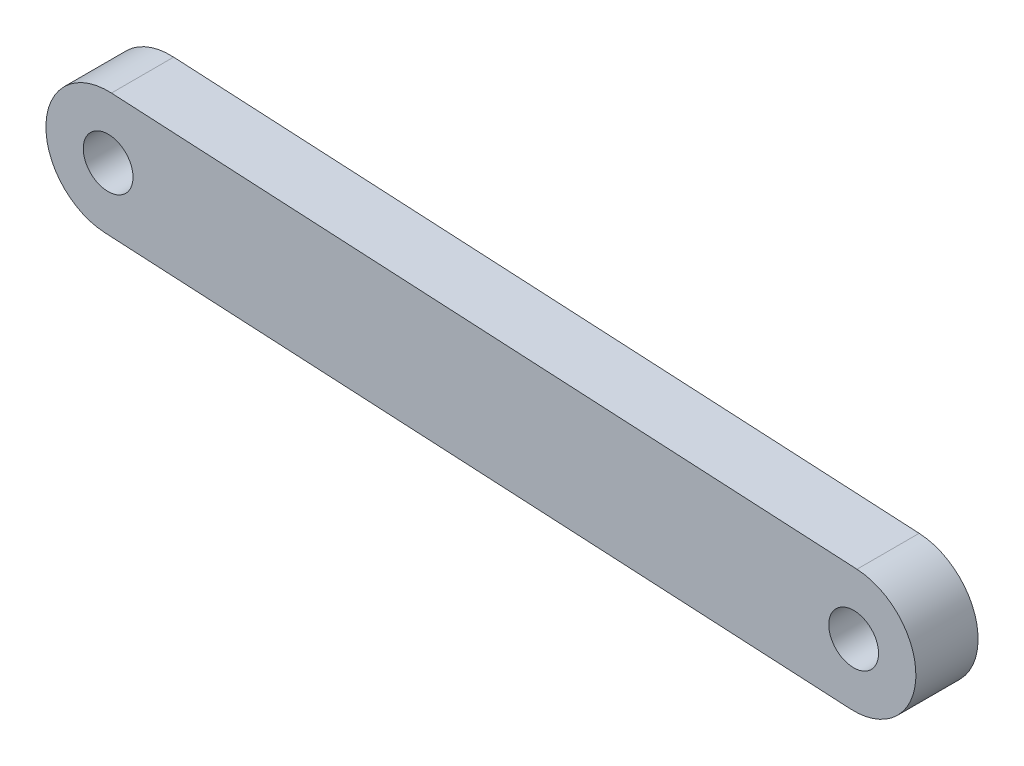
from build123d import *

# Parameters (mm, degrees)
SKETCH1_R           = 2
BOSS_EXTRUDE1_DEPTH = 5


with BuildPart() as part:
    # Sketch1 → Boss-Extrude1 (new body)
    with BuildSketch(Plane(origin=(0, 0, 0), x_dir=(0.431181775, 0.902265081, 0), z_dir=(0, 0, 1))):
        with BuildLine():
            Line((-18.654834307, 30.177729369), (-41.615840249, 85.610501319))
            ThreePointArc((-41.615840249, 85.610501319), (-48.148655073, 88.31648182), (-50.854635574, 81.783666996))
            Line((-50.854635574, 81.783666996), (-27.893629632, 26.350895045))
            ThreePointArc((-27.893629632, 26.350895045), (-21.360814808, 23.644914544), (-18.654834307, 30.177729369))
        make_face()
        with Locations((-23.27423197, 28.264312207)):
            Circle(SKETCH1_R, mode=Mode.SUBTRACT)
        with Locations((-46.235237911, 83.697084158)):
            Circle(SKETCH1_R, mode=Mode.SUBTRACT)
    extrude(amount=BOSS_EXTRUDE1_DEPTH)


solid = part.part
